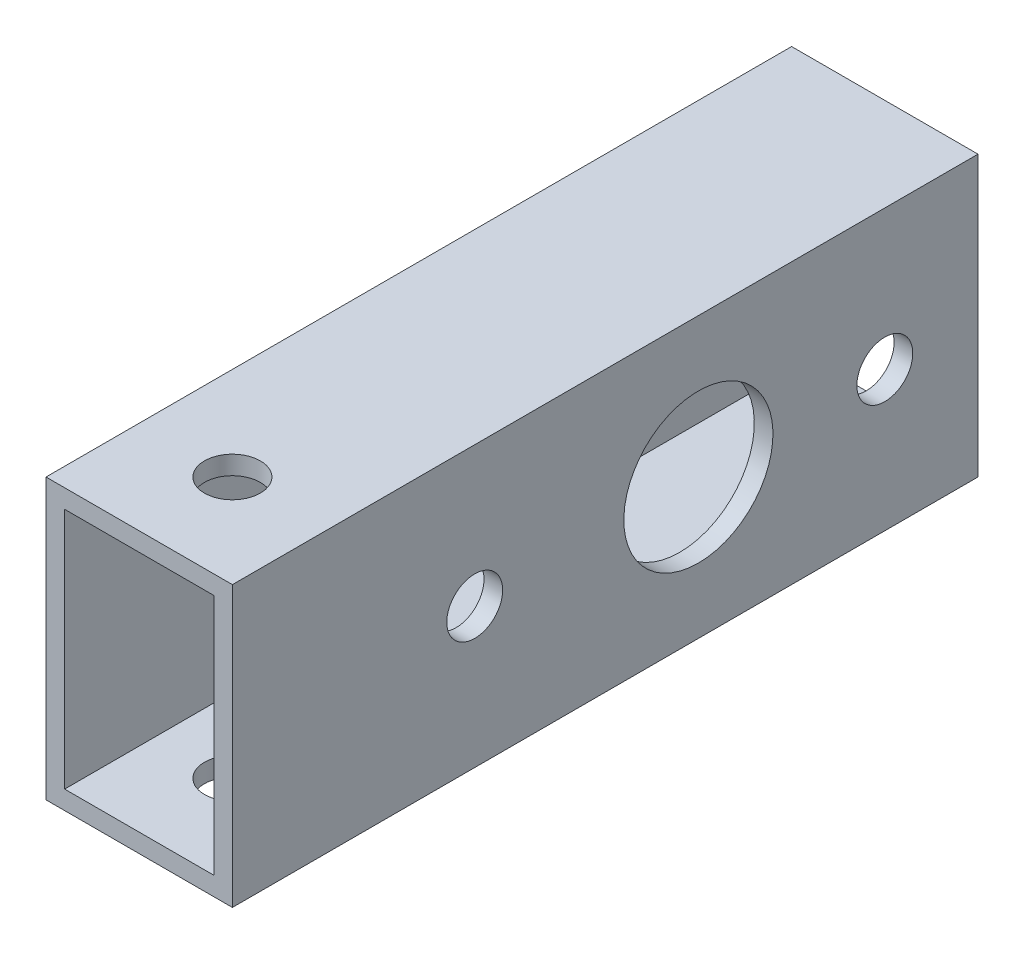
from build123d import *

# Parameters (mm, degrees)
SKETCH_1_W          = 10
SKETCH_1_H          = 15
SKETCH_1_W_2        = 8
SKETCH_1_H_2        = 13
EXTRUDE_1_DEPTH     = 40
SKETCH_2_R          = 1.5
SKETCH_2_R_2        = 4
CUT_EXTRUDE_1_DEPTH = 11
SKETCH_3_R          = 1.5
CUT_EXTRUDE_2_DEPTH = 16


with BuildPart() as part:
    # 草图1 → 拉伸-薄壁1 (new body)
    with BuildSketch(Plane.XY):
        with Locations((88.100313923, 48.436702161)):
            Rectangle(SKETCH_1_W, SKETCH_1_H)
        with Locations((88.100313923, 48.436702161)):
            Rectangle(SKETCH_1_W_2, SKETCH_1_H_2, mode=Mode.SUBTRACT)
    extrude(amount=EXTRUDE_1_DEPTH)

    # 草图2 → 切除-拉伸1 (cut, through all)
    with BuildSketch(Plane.ZY.offset(-83.100313923)):
        with Locations((5, 48.436702161)):
            Circle(SKETCH_2_R)
        with Locations((27, 48.436702161)):
            Circle(SKETCH_2_R)
        with Locations((15, 48.436702161)):
            Circle(SKETCH_2_R_2)
    extrude(amount=-CUT_EXTRUDE_1_DEPTH, mode=Mode.SUBTRACT)

    # 草图3 → 切除-拉伸2 (cut, through all)
    with BuildSketch(Plane.XZ.offset(-40.936702161)):
        with Locations((88.100313923, 35)):
            Circle(SKETCH_3_R)
    extrude(amount=-CUT_EXTRUDE_2_DEPTH, mode=Mode.SUBTRACT)


solid = part.part
